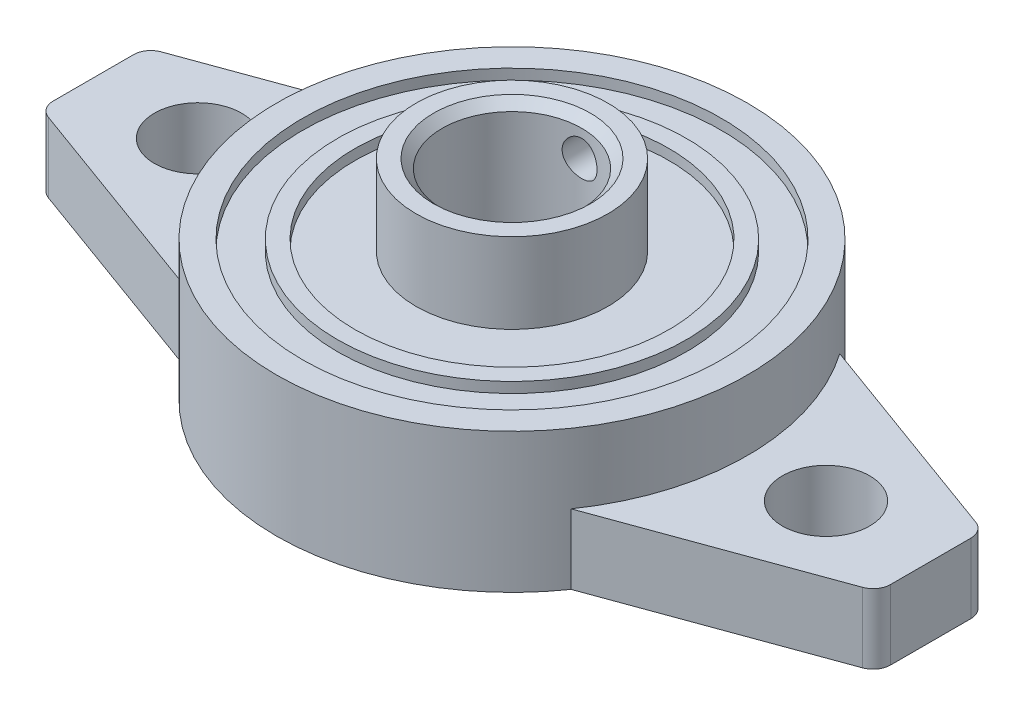
from build123d import *

# Parameters (mm, degrees)
SKETCH_1_R          = 2.5
EXTRUDE_1_DEPTH     = 4
SKETCH_2_R          = 13.5
EXTRUDE_2_DEPTH     = 4
SKETCH_3_R          = 5.5
EXTRUDE_3_DEPTH     = 4
SKETCH_4_R          = 4
CUT_EXTRUDE_1_DEPTH = 13
SKETCH_5_R          = 12
SKETCH_5_R_2        = 10
SKETCH_5_R_3        = 9
SKETCH_5_R_4        = 5.5
CUT_EXTRUDE_2_DEPTH = 0.6
SKETCH_8_R          = 12.5
CUT_EXTRUDE_4_DEPTH = 1
SKETCH_9_R          = 1
CUT_EXTRUDE_5_DEPTH = 14.5
CHAMFER_1_SIZE      = 0.5


with BuildPart() as part:
    # 草图1 → 凸台-拉伸1 (new body)
    with BuildSketch(Plane(origin=(0, 0, 0), x_dir=(1, 0, 0), z_dir=(0, 1, 0))):
        with BuildLine():
            Line((24, -2.299792462), (24, 2.299792462))
            ThreePointArc((24, 2.299792462), (23.819152044, 2.873368898), (23.342020143, 3.239485083))
            Line((23.342020143, 3.239485083), (11.089367754, 7.699085843))
            ThreePointArc((11.089367754, 7.699085843), (0, 13.5), (-11.089367754, 7.699085843))
            Line((-11.089367754, 7.699085843), (-23.342020143, 3.239485083))
            ThreePointArc((-23.342020143, 3.239485083), (-23.819152044, 2.873368898), (-24, 2.299792462))
            Line((-24, 2.299792462), (-24, -2.299792462))
            ThreePointArc((-24, -2.299792462), (-23.819152044, -2.873368898), (-23.342020143, -3.239485083))
            Line((-23.342020143, -3.239485083), (-11.089367754, -7.699085843))
            ThreePointArc((-11.089367754, -7.699085843), (0, -13.5), (11.089367754, -7.699085843))
            Line((11.089367754, -7.699085843), (23.342020143, -3.239485083))
            ThreePointArc((23.342020143, -3.239485083), (23.819152044, -2.873368898), (24, -2.299792462))
        make_face()
        with Locations((-18, 0)):
            Circle(SKETCH_1_R, mode=Mode.SUBTRACT)
        with Locations((18, 0)):
            Circle(SKETCH_1_R, mode=Mode.SUBTRACT)
    extrude(amount=EXTRUDE_1_DEPTH)

    # 草图2 → 凸台-拉伸2 (add)
    with BuildSketch(Plane(origin=(0, 4, 0), x_dir=(1, 0, 0), z_dir=(0, 1, 0))):
        Circle(SKETCH_2_R)
    extrude(amount=EXTRUDE_2_DEPTH)

    # 草图3 → 凸台-拉伸3 (add)
    with BuildSketch(Plane(origin=(0, 8, 0), x_dir=(1, 0, 0), z_dir=(0, 1, 0))):
        Circle(SKETCH_3_R)
    extrude(amount=EXTRUDE_3_DEPTH)

    # 草图4 → 切除-拉伸1 (cut, through all)
    with BuildSketch(Plane(origin=(0, 12, 0), x_dir=(1, 0, 0), z_dir=(0, 1, 0))):
        Circle(SKETCH_4_R)
    extrude(amount=-CUT_EXTRUDE_1_DEPTH, mode=Mode.SUBTRACT)

    # 草图5 → 切除-拉伸2 (cut)
    with BuildSketch(Plane(origin=(0, 8, 0), x_dir=(1, 0, 0), z_dir=(0, 1, 0))):
        Circle(SKETCH_5_R)
        Circle(SKETCH_5_R_2, mode=Mode.SUBTRACT)
        Circle(SKETCH_5_R_3)
        Circle(SKETCH_5_R_4, mode=Mode.SUBTRACT)
    extrude(amount=-CUT_EXTRUDE_2_DEPTH, mode=Mode.SUBTRACT)

    # 草图8 → 切除-拉伸4 (cut)
    with BuildSketch(Plane.XZ):
        Circle(SKETCH_8_R)
    extrude(amount=-CUT_EXTRUDE_4_DEPTH, mode=Mode.SUBTRACT)

    # 草图9 → 切除-拉伸5 (cut, through all)
    with BuildSketch(Plane.XY):
        with Locations((0, 10)):
            Circle(SKETCH_9_R)
    extrude(amount=-CUT_EXTRUDE_5_DEPTH, mode=Mode.SUBTRACT)

    # 倒角1
    chamfer_1_edges = [part.edges().sort_by_distance(p)[0] for p in [
        (-4, 12, 0),
        (-4, 1, 0),
    ]]
    chamfer(chamfer_1_edges, length=CHAMFER_1_SIZE)


solid = part.part
